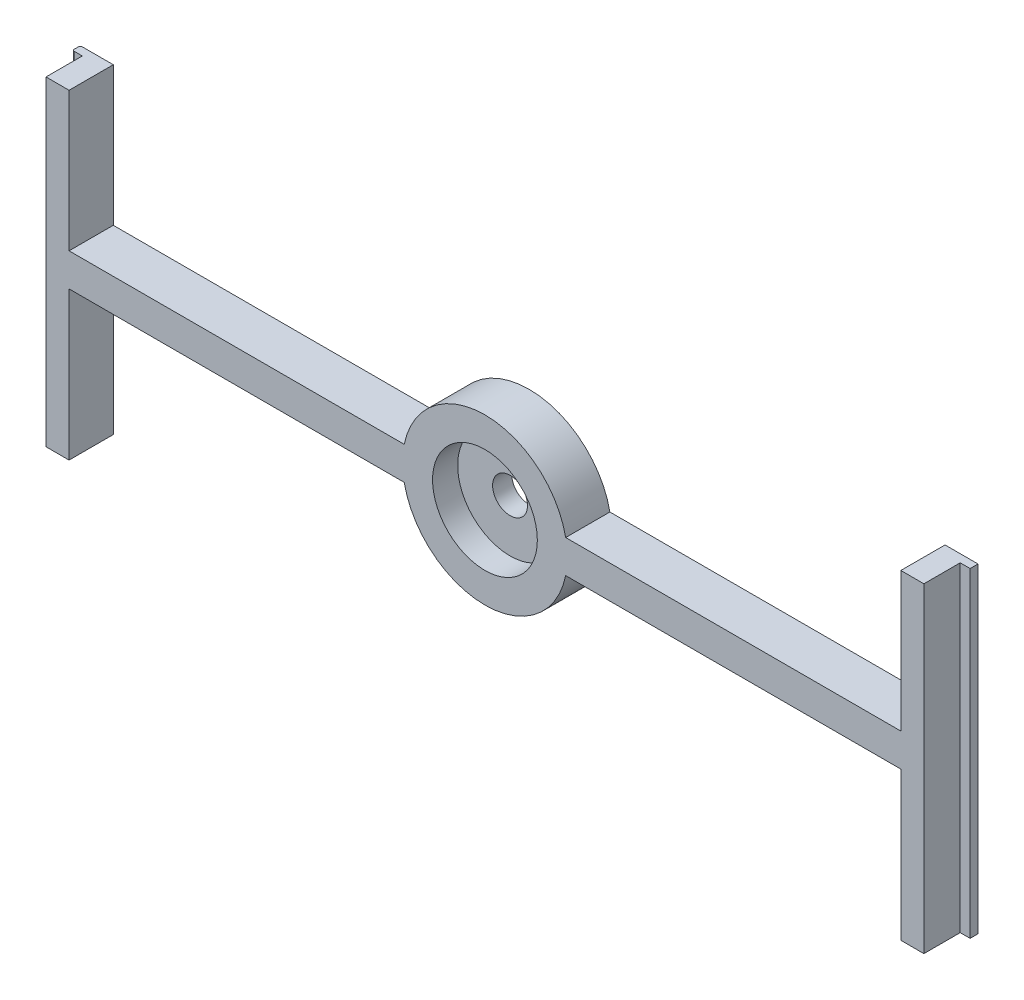
from build123d import *

# Parameters (mm, degrees)
BOSS_EXTRUDE1_DEPTH = 6.71
SKETCH2_W           = 1.5
SKETCH2_H           = 5.51
CUT_EXTRUDE1_DEPTH  = 51
SKETCH3_R           = 7.9502
CUT_EXTRUDE2_DEPTH  = 3.81
SKETCH4_W           = 136.2
SKETCH4_H           = 1.4
CUT_EXTRUDE3_DEPTH  = 7.71
SKETCH5_R           = 2.65
CUT_EXTRUDE4_DEPTH  = 3.9
FILLET1_R           = 0.3


with BuildPart() as part:
    # Sketch1 → Boss-Extrude1 (new body)
    with BuildSketch(Plane.XY):
        with BuildLine():
            Line((-63.1, 2.5), (-12.247448714, 2.5))
            ThreePointArc((-12.247448714, 2.5), (0, 12.5), (12.247448714, 2.5))
            Line((12.247448714, 2.5), (63.1, 2.5))
            Line((63.1, 2.5), (63.1, 25))
            Line((63.1, 25), (68.1, 25))
            Line((68.1, 25), (68.1, -25))
            Line((68.1, -25), (63.1, -25))
            Line((63.1, -25), (63.1, -2.5))
            Line((63.1, -2.5), (12.247448714, -2.5))
            ThreePointArc((12.247448714, -2.5), (0, -12.5), (-12.247448714, -2.5))
            Line((-12.247448714, -2.5), (-63.1, -2.5))
            Line((-63.1, -2.5), (-63.1, -25))
            Line((-63.1, -25), (-68.1, -25))
            Line((-68.1, -25), (-68.1, 25))
            Line((-68.1, 25), (-63.1, 25))
            Line((-63.1, 25), (-63.1, 2.5))
        make_face()
    extrude(amount=BOSS_EXTRUDE1_DEPTH)

    # Sketch2 → Cut-Extrude1 (cut, through all)
    with BuildSketch(Plane.XZ.offset(25)):
        with Locations((67.35, 3.955)):
            Rectangle(SKETCH2_W, SKETCH2_H)
        with Locations((-67.35, 3.955)):
            Rectangle(SKETCH2_W, SKETCH2_H)
    extrude(amount=-CUT_EXTRUDE1_DEPTH, mode=Mode.SUBTRACT)

    # Sketch3 → Cut-Extrude2 (cut)
    with BuildSketch(Plane.XY.offset(6.71)):
        Circle(SKETCH3_R)
    extrude(amount=-CUT_EXTRUDE2_DEPTH, mode=Mode.SUBTRACT)

    # Sketch4 → Cut-Extrude3 (cut, through all)
    with BuildSketch(Plane.XY.offset(6.71)):
        with Locations((0, 24.3)):
            Rectangle(SKETCH4_W, SKETCH4_H)
    extrude(amount=-CUT_EXTRUDE3_DEPTH, mode=Mode.SUBTRACT)

    # Sketch5 → Cut-Extrude4 (cut, through all)
    with BuildSketch(Plane.XY.offset(2.9)):
        Circle(SKETCH5_R)
    extrude(amount=-CUT_EXTRUDE4_DEPTH, mode=Mode.SUBTRACT)

    # Fillet1
    fillet1_edges = [part.edges().sort_by_distance(p)[0] for p in [
        (-68.1, -0.7, 1.2),
        (-68.1, -0.7, 0),
    ]]
    fillet(fillet1_edges, radius=FILLET1_R)


solid = part.part
